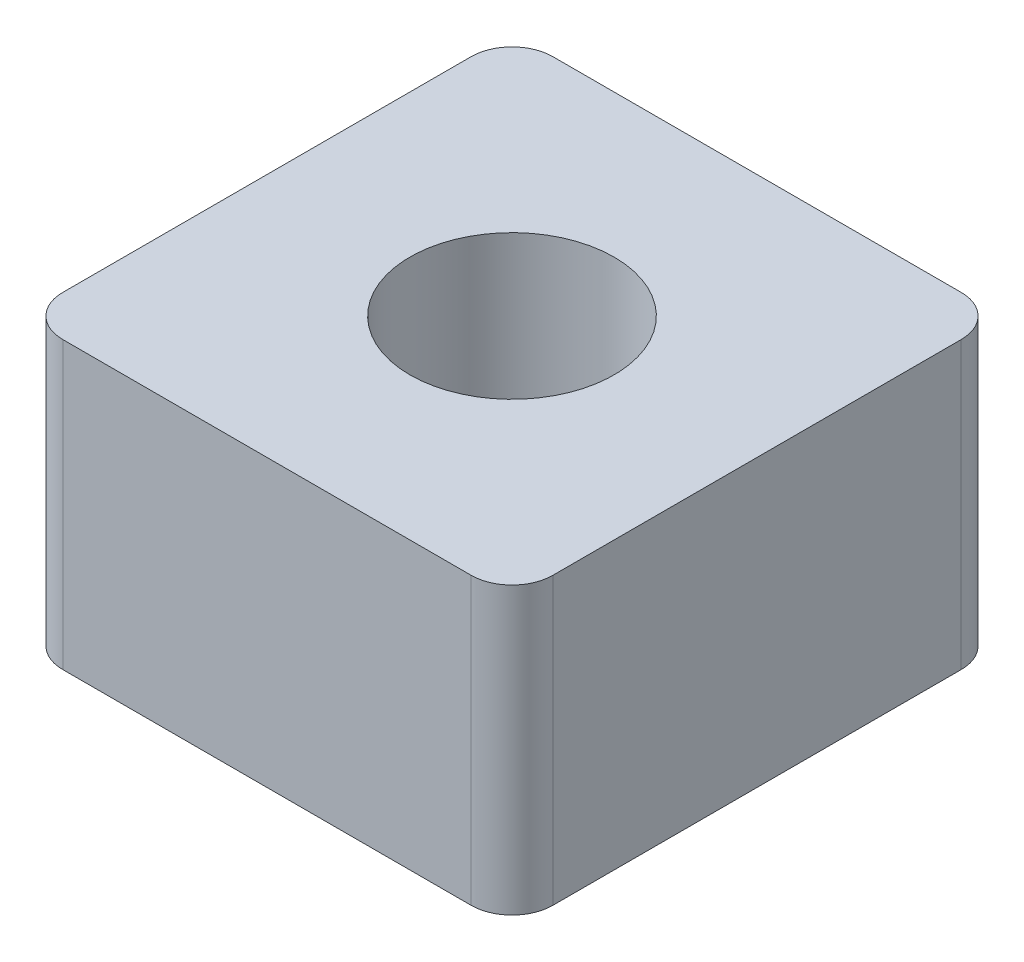
from build123d import *

# Parameters (mm, degrees)
BOSS_EXTRUDE1_DEPTH = 70
SKETCH4_R           = 25
CUT_EXTRUDE4_DEPTH  = 71


with BuildPart() as part:
    # Sketch2 → Boss-Extrude1 (new body)
    with BuildSketch(Plane(origin=(0, 0, 0), x_dir=(1, 0, 0), z_dir=(0, 1, 0))):
        with BuildLine():
            Line((-50, -60), (50, -60))
            ThreePointArc((50, -60), (57.071067812, -57.071067812), (60, -50))
            Line((60, -50), (60, 50))
            ThreePointArc((60, 50), (57.071067812, 57.071067812), (50, 60))
            Line((50, 60), (-50, 60))
            ThreePointArc((-50, 60), (-57.071067812, 57.071067812), (-60, 50))
            Line((-60, 50), (-60, -50))
            ThreePointArc((-60, -50), (-57.071067812, -57.071067812), (-50, -60))
        make_face()
    extrude(amount=BOSS_EXTRUDE1_DEPTH)

    # Sketch4 → Cut-Extrude4 (cut, through all)
    with BuildSketch(Plane.XZ):
        Circle(SKETCH4_R)
    extrude(amount=-CUT_EXTRUDE4_DEPTH, mode=Mode.SUBTRACT)


solid = part.part
